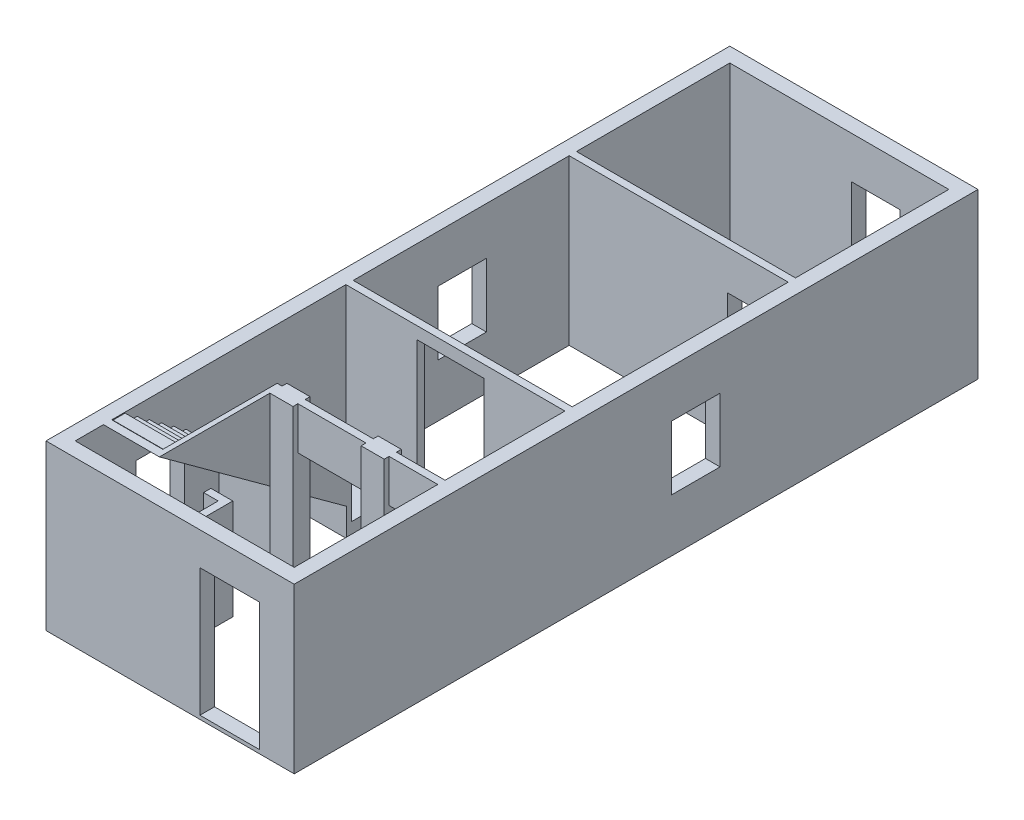
from build123d import *

# Parameters (mm, degrees)
SKETCH_1_W                = 4080
SKETCH_1_H                = 11240
SKETCH_1_W_2              = 3600
SKETCH_1_H_2              = 10760
EXTRUDE_512_DEPTH         = 2700
SKETCH_6_W                = 3600
SKETCH_6_H                = 120
EXTRUDE_823_DEPTH         = 2700
SKETCH_12_W               = 1240
SKETCH_12_H               = 120
EXTRUDE_1044_DEPTH        = 2220
CUT_EXTRUDE_1283_REACH    = 2882
SKETCH_10_W               = 800
SKETCH_10_H               = 2050
SKETCH_7_W                = 3600
SKETCH_7_H                = 120
EXTRUDE_1405_DEPTH        = 2700
CUT_EXTRUDE_1668_REACH    = 6552
SKETCH_13_W               = 1100
SKETCH_13_H               = 2400
SKETCH_8_W                = 3600
SKETCH_8_H                = 120
EXTRUDE_1790_DEPTH        = 2700
EXTRUDE_2112_DEPTH        = 840
EXTRUDE_2407_DEPTH        = 80
CUT_EXTRUDE_2805_REACH    = 2702
SKETCH_19_W               = 840
SKETCH_19_H               = 120
EXTRUDE_2943_DEPTH        = 1650
EXTRUDE_3217_DEPTH        = 840
PATTERN_LINEAR_3276_COUNT = 15
PATTERN_LINEAR_3276_PITCH = 247.44
SKETCH_22_W               = 920
SKETCH_22_H               = 830
EXTRUDE_7_DEPTH           = 200
EXTRUDE_8_DEPTH           = 200
SKETCH_14_W               = 380
SKETCH_14_H               = 280
EXTRUDE_3881_DEPTH        = 2700
CUT_EXTRUDE_4195_REACH    = 8642
SKETCH_15_W               = 800
SKETCH_15_H               = 2000
SKETCH_15_W_2             = 1120
SKETCH_2_W                = 980
SKETCH_2_H                = 2100
CUT_EXTRUDE_4473_DEPTH    = 241
SKETCH_4_W                = 800
SKETCH_4_H                = 1050
CUT_EXTRUDE_4728_DEPTH    = 241
SKETCH_3_W                = 800
SKETCH_3_H                = 1050
CUT_EXTRUDE_5092_DEPTH    = 4080
CUT_EXTRUDE_5326_REACH    = 242
SKETCH_16_W               = 800
SKETCH_16_H               = 1050


with BuildPart() as part:
    # 草图1 → Extrude 512 (new body)
    with BuildSketch(Plane(origin=(0, 0, 0), x_dir=(1, 0, 0), z_dir=(0, 1, 0))):
        with Locations((-1800, 5380)):
            Rectangle(SKETCH_1_W, SKETCH_1_H)
        with Locations((-1800, 5380)):
            Rectangle(SKETCH_1_W_2, SKETCH_1_H_2, mode=Mode.SUBTRACT)
    extrude(amount=EXTRUDE_512_DEPTH)

    # 草图6 → Extrude 823 (add)
    with BuildSketch(Plane(origin=(0, 0, 0), x_dir=(1, 0, 0), z_dir=(0, 1, 0))):
        with Locations((-1800, 8180)):
            Rectangle(SKETCH_6_W, SKETCH_6_H)
    extrude(amount=EXTRUDE_823_DEPTH)

    # 草图12 → Extrude 1044 (add)
    with BuildSketch(Plane(origin=(0, 0, 0), x_dir=(1, 0, 0), z_dir=(0, 1, 0))):
        with Locations((-620, 8300)):
            Rectangle(SKETCH_12_W, SKETCH_12_H)
    extrude(amount=EXTRUDE_1044_DEPTH)

    # 草图10 → Cut-Extrude 1283 (cut, up to next)
    with BuildSketch(Plane.XY.offset(-8120), mode=Mode.PRIVATE) as cut_extrude_1283_sk1:
        with Locations((-600, 1025)):
            Rectangle(SKETCH_10_W, SKETCH_10_H)
    cut_extrude_1283_tool1 = extrude(cut_extrude_1283_sk1.sketch, amount=-CUT_EXTRUDE_1283_REACH, mode=Mode.PRIVATE) & part.part
    add(cut_extrude_1283_tool1.solids().sort_by_distance((-600, 1025, -8120))[0], mode=Mode.SUBTRACT)

    # 草图7 → Extrude 1405 (add)
    with BuildSketch(Plane(origin=(0, 0, 0), x_dir=(1, 0, 0), z_dir=(0, 1, 0))):
        with Locations((-1800, 4510)):
            Rectangle(SKETCH_7_W, SKETCH_7_H)
    extrude(amount=EXTRUDE_1405_DEPTH)

    # 草图13 → Cut-Extrude 1668 (cut, up to next)
    with BuildSketch(Plane.XY.offset(-4450), mode=Mode.PRIVATE) as cut_extrude_1668_sk1:
        with Locations((-1880, 1300)):
            Rectangle(SKETCH_13_W, SKETCH_13_H)
    cut_extrude_1668_tool1 = extrude(cut_extrude_1668_sk1.sketch, amount=-CUT_EXTRUDE_1668_REACH, mode=Mode.PRIVATE) & part.part
    add(cut_extrude_1668_tool1.solids().sort_by_distance((-1880, 1300, -4450))[0], mode=Mode.SUBTRACT)

    # 草图8 → Extrude 1790 (add)
    with BuildSketch(Plane(origin=(0, 0, 0), x_dir=(1, 0, 0), z_dir=(0, 1, 0))):
        with Locations((-1800, 2420)):
            Rectangle(SKETCH_8_W, SKETCH_8_H)
    extrude(amount=EXTRUDE_1790_DEPTH)

    # 草图17 → Extrude 2112 (add)
    with BuildSketch(Plane(origin=(-3600, 0, 0), x_dir=(0, 0, -1), z_dir=(1, 0, 0))):
        Polygon((464.132296, 2700), (3540, 459.301672), (3540, 0), (3620, 0), (3620, 500), (600, 2700), align=None)
    extrude(amount=EXTRUDE_2112_DEPTH)

    # 草图18 → Extrude 2407 (add)
    with BuildSketch(Plane(origin=(-2760, 0, 0), x_dir=(0, 0, -1), z_dir=(1, 0, 0))):
        Polygon((464.132296, 2700), (3540, 459.301672), (3540, 0), (3620, 0), (3620, 1420), (2480, 2250.463576), (2480, 2700), align=None)
    extrude(amount=EXTRUDE_2407_DEPTH)

    # Cut-Extrude 2805: up to this face of the body (flat: up to its plane)
    cut_extrude_2805_end = Plane(part.part.faces().sort_by_distance((-3180, 2058.940397, -1480))[0])
    # 草图19 → Cut-Extrude 2805 (cut, up to the picked face)
    with BuildSketch(Plane(origin=(0, 2700, 0), x_dir=(1, 0, 0), z_dir=(0, 1, 0)), mode=Mode.PRIVATE) as cut_extrude_2805_sk1:
        with Locations((-3180, 2420)):
            Rectangle(SKETCH_19_W, SKETCH_19_H)
    cut_extrude_2805_tool1 = split(extrude(cut_extrude_2805_sk1.sketch, amount=-CUT_EXTRUDE_2805_REACH, mode=Mode.PRIVATE), bisect_by=cut_extrude_2805_end, keep=Keep.BOTH, mode=Mode.PRIVATE)
    add(cut_extrude_2805_tool1.solids().sort_by_distance((-3180, 2700, -2420))[0], mode=Mode.SUBTRACT)

    # 草图20 → Extrude 2943 (add)
    with BuildSketch(Plane(origin=(0, 0, 0), x_dir=(1, 0, 0), z_dir=(0, 1, 0))):
        Polygon((-2860, 1490), (-2500, 1490), (-2500, 0), (-2620, 0), (-2620, 1370), (-2860, 1370), align=None)
    extrude(amount=EXTRUDE_2943_DEPTH)

    # 草图21 → Extrude 3217 (add)
    with BuildSketch(Plane(origin=(-3600, 0, 0), x_dir=(0, 0, -1), z_dir=(1, 0, 0))):
        Polygon((3620, 500), (3620, 645.695364), (3420, 645.695364), align=None)
    extrude_3217 = extrude(amount=EXTRUDE_3217_DEPTH)

    # Pattern Linear 3276: Extrude 3217 ×15
    with Locations(*[Vector(0, 0.588808, 0.808273) * (i * PATTERN_LINEAR_3276_PITCH) for i in range(1, PATTERN_LINEAR_3276_COUNT)]):
        add(extrude_3217)

    # 草图22 → 凸台-拉伸7 (add)
    with BuildSketch(Plane(origin=(0, 0, 0), x_dir=(1, 0, 0), z_dir=(0, 1, 0))):
        with Locations((-3140, 4035)):
            Rectangle(SKETCH_22_W, SKETCH_22_H)
    extrude(amount=EXTRUDE_7_DEPTH)

    # 草图23 → 凸台-拉伸8 (add)
    with BuildSketch(Plane(origin=(0, 200, 0), x_dir=(1, 0, 0), z_dir=(0, 1, 0))):
        Polygon((-3600, 4450), (-3600, 3620), (-2680, 3620), align=None)
    extrude(amount=EXTRUDE_8_DEPTH)

    # 草图14 → Extrude 3881 (add)
    with BuildSketch(Plane(origin=(0, 0, 0), x_dir=(1, 0, 0), z_dir=(0, 1, 0))):
        with Locations((-990, 2420)):
            Rectangle(SKETCH_14_W, SKETCH_14_H)
        with Locations((-2490, 2420)):
            Rectangle(SKETCH_14_W, SKETCH_14_H)
    extrude(amount=EXTRUDE_3881_DEPTH)

    # 草图15 → Cut-Extrude 4195 (cut, up to next)
    with BuildSketch(Plane.XY.offset(-2360), mode=Mode.PRIVATE) as cut_extrude_4195_sk1:
        with Locations((-400, 1000)):
            Rectangle(SKETCH_15_W, SKETCH_15_H)
    cut_extrude_4195_tool1 = extrude(cut_extrude_4195_sk1.sketch, amount=-CUT_EXTRUDE_4195_REACH, mode=Mode.PRIVATE) & part.part
    add(cut_extrude_4195_tool1.solids().sort_by_distance((-400, 1000, -2360))[0], mode=Mode.SUBTRACT)
    # 草图15 → Cut-Extrude 4195 (cut, up to next)
    with BuildSketch(Plane.XY.offset(-2360), mode=Mode.PRIVATE) as cut_extrude_4195_sk2:
        with Locations((-1740, 1000)):
            Rectangle(SKETCH_15_W_2, SKETCH_15_H)
    cut_extrude_4195_tool2 = extrude(cut_extrude_4195_sk2.sketch, amount=-CUT_EXTRUDE_4195_REACH, mode=Mode.PRIVATE) & part.part
    add(cut_extrude_4195_tool2.solids().sort_by_distance((-1740, 1000, -2360))[0], mode=Mode.SUBTRACT)

    # 草图2 → Cut-Extrude 4473 (cut, through all)
    with BuildSketch(Plane(origin=(0, 0, 0), x_dir=(-1, 0, 0), z_dir=(0, 0, -1))):
        with Locations((820, 1110)):
            Rectangle(SKETCH_2_W, SKETCH_2_H)
    extrude(amount=-CUT_EXTRUDE_4473_DEPTH, mode=Mode.SUBTRACT)

    # 草图4 → Cut-Extrude 4728 (cut, through all)
    with BuildSketch(Plane.XY.offset(-10760)):
        with Locations((-1200, 1485)):
            Rectangle(SKETCH_4_W, SKETCH_4_H)
    extrude(amount=-CUT_EXTRUDE_4728_DEPTH, mode=Mode.SUBTRACT)

    # 草图3 → Cut-Extrude 5092 (cut)
    with BuildSketch(Plane.ZY.offset(-240)):
        with Locations((-6360, 1395)):
            Rectangle(SKETCH_3_W, SKETCH_3_H)
    extrude(amount=CUT_EXTRUDE_5092_DEPTH, mode=Mode.SUBTRACT)

    # 草图16 → Cut-Extrude 5326 (cut, up to next)
    with BuildSketch(Plane(origin=(-3600, 0, 0), x_dir=(0, 0, -1), z_dir=(1, 0, 0)), mode=Mode.PRIVATE) as cut_extrude_5326_sk1:
        with Locations((1400, 1395)):
            Rectangle(SKETCH_16_W, SKETCH_16_H)
    cut_extrude_5326_tool1 = extrude(cut_extrude_5326_sk1.sketch, amount=-CUT_EXTRUDE_5326_REACH, mode=Mode.PRIVATE) & part.part
    add(cut_extrude_5326_tool1.solids().sort_by_distance((-3600, 1395, -1400))[0], mode=Mode.SUBTRACT)


solid = part.part
